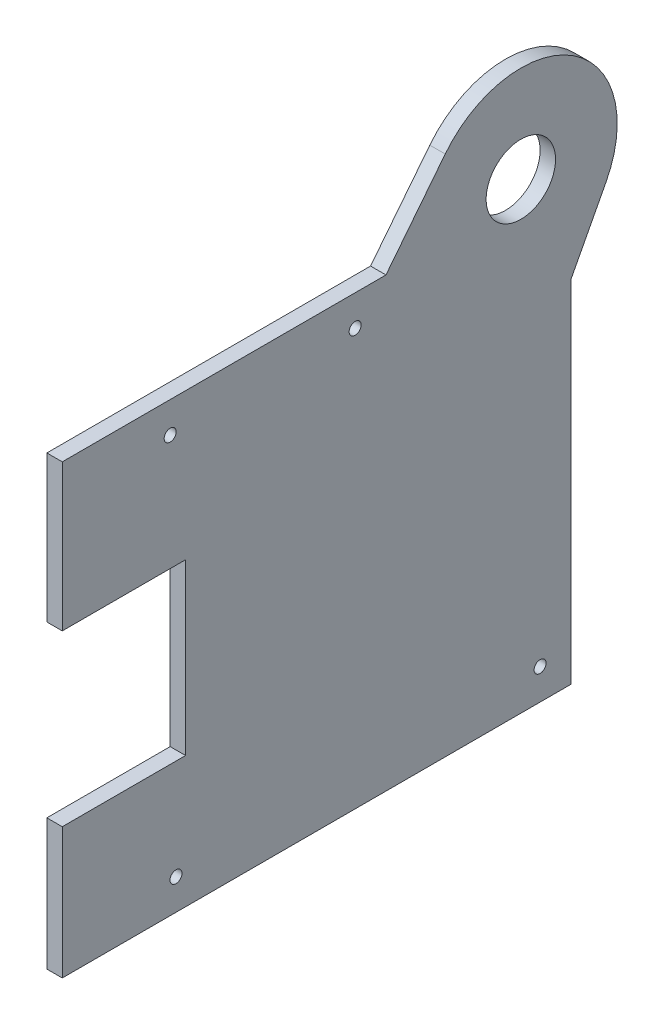
from build123d import *

# Parameters (mm, degrees)
SKETCH1_R               = 14.2875
BOSS_EXTRUDE1_DEPTH     = 6.35
SKETCH2_W               = 133.35
SKETCH2_H               = 44.45
CUT_EXTRUDE1_DEPTH      = 7.35
CUT_EXTRUDE2_DEPTH      = 7.35
BOSS_EXTRUDE2_DEPTH     = 6.35
SKETCH4_R               = 2.4765
CUT_EXTRUDE3_DEPTH      = 2.54
CUT_EXTRUDE3_DEPTH_BACK = 7.35


with BuildPart() as part:
    # Sketch1 → Boss-Extrude1 (new body)
    with BuildSketch(Plane(origin=(0, 0, 0), x_dir=(0, 0, -1), z_dir=(1, 0, 0))):
        Polygon((-104.775, -60.325), (-104.775, -114.3), (104.775, -114.3), (104.775, 114.3), (-104.775, 114.3), (-104.775, 9.525), (-53.975, 9.525), (-53.975, -60.325), align=None)
        with Locations((84.1375, 76.2)):
            Circle(SKETCH1_R, mode=Mode.SUBTRACT)
    extrude(amount=BOSS_EXTRUDE1_DEPTH)

    # Sketch2 → Cut-Extrude1 (cut, through all)
    with BuildSketch(Plane(origin=(6.35, 0, 0), x_dir=(0, 0, -1), z_dir=(1, 0, 0))):
        with Locations((-38.1, 92.075)):
            Rectangle(SKETCH2_W, SKETCH2_H)
    extrude(amount=-CUT_EXTRUDE1_DEPTH, mode=Mode.SUBTRACT)

    # Sketch3 → Cut-Extrude2 (cut, through all)
    with BuildSketch(Plane(origin=(6.35, 0, 0), x_dir=(0, 0, -1), z_dir=(1, 0, 0))):
        with BuildLine():
            Line((28.575, 114.3), (28.575, 69.85))
            Line((28.575, 69.85), (52.979857871, 100.782493632))
            ThreePointArc((52.979857871, 100.782493632), (61.948043641, 109.10479726), (73.025, 114.3))
            Line((73.025, 114.3), (28.575, 114.3))
        make_face()
        with BuildLine():
            Line((104.775, 114.3), (95.25, 114.3))
            ThreePointArc((95.25, 114.3), (100.150813391, 112.513516085), (104.775, 110.09972345))
            Line((104.775, 110.09972345), (104.775, 114.3))
        make_face()
    extrude(amount=-CUT_EXTRUDE2_DEPTH, mode=Mode.SUBTRACT)

    # Sketch3_3 → Boss-Extrude2 (add)
    with BuildSketch(Plane(origin=(6.35, 0, 0), x_dir=(0, 0, -1), z_dir=(1, 0, 0))):
        with BuildLine():
            ThreePointArc((119.268927195, 57.73705117), (113.070471033, 49.034197169), (104.775, 42.30027655))
            Line((104.775, 42.30027655), (104.775, 30.157905893))
            Line((104.775, 30.157905893), (119.268927195, 57.73705117))
        make_face()
        with BuildLine():
            Line((104.775, 110.09972345), (104.775, 42.30027655))
            ThreePointArc((104.775, 42.30027655), (113.070471033, 49.034197169), (119.268927195, 57.73705117))
            ThreePointArc((119.268927195, 57.73705117), (122.669150452, 66.691605303), (123.825, 76.2))
            ThreePointArc((123.825, 76.2), (118.736260364, 95.642824833), (104.775, 110.09972345))
        make_face()
        with BuildLine():
            ThreePointArc((95.25, 114.3), (84.1375, 115.8875), (73.025, 114.3))
            Line((73.025, 114.3), (95.25, 114.3))
        make_face()
    extrude(amount=-BOSS_EXTRUDE2_DEPTH)

    # Sketch4 → Cut-Extrude3 (cut, two sides)
    with BuildSketch(Plane(origin=(6.35, 0, 0), x_dir=(0, 0, -1), z_dir=(1, 0, 0))) as cut_extrude3_sk:
        with Locations((-60.325, 57.15)):
            Circle(SKETCH4_R)
        with Locations((15.875, 57.15)):
            Circle(SKETCH4_R)
        with Locations((92.075, -101.6)):
            Circle(SKETCH4_R)
        with Locations((-57.925, -101.6)):
            Circle(SKETCH4_R)
    extrude(amount=CUT_EXTRUDE3_DEPTH, mode=Mode.SUBTRACT)
    extrude(cut_extrude3_sk.sketch, amount=-CUT_EXTRUDE3_DEPTH_BACK, mode=Mode.SUBTRACT)


solid = part.part
